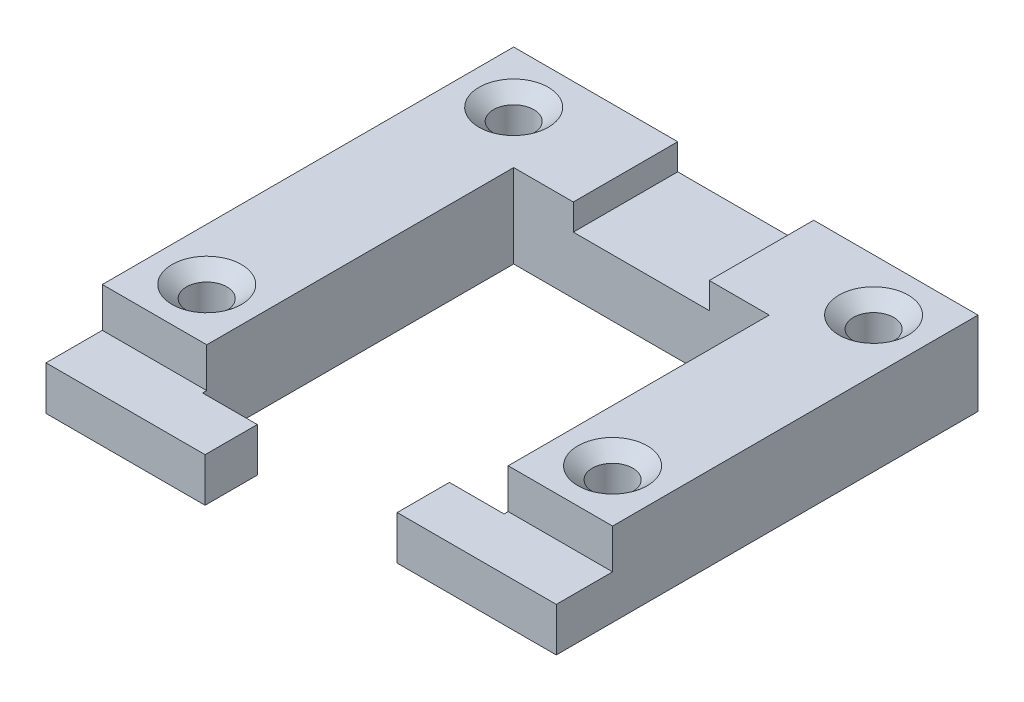
from build123d import *

# Parameters (mm, degrees)
BOSS_EXTRUDE1_DEPTH                               = 10.16
CSK_FOR_8_FLAT_HEAD_MACHINE_SCREW_100_D           = 4.9149
CSK_FOR_8_FLAT_HEAD_MACHINE_SCREW_100_CSINK_D     = 8.4328
CSK_FOR_8_FLAT_HEAD_MACHINE_SCREW_100_CSINK_ANGLE = 100
SKETCH5_W                                         = 16.54
SKETCH5_H                                         = 3.175
CUT_EXTRUDE1_DEPTH                                = 51.038
SKETCH6_W                                         = 12.7
SKETCH6_H                                         = 0.5
BOSS_EXTRUDE2_DEPTH                               = 5.334


with BuildPart() as part:
    # Sketch1 → Boss-Extrude1 (new body)
    with BuildSketch(Plane(origin=(0, 19.05, 0), x_dir=(1, 0, 0), z_dir=(0, 1, 0))):
        Polygon((15.54, 76.2), (15.54, 44.45), (28.24, 44.45), (28.24, 88.9), (-28.24, 88.9), (-28.24, 38.862), (-15.54, 38.862), (-15.54, 76.2), align=None)
    extrude(amount=BOSS_EXTRUDE1_DEPTH)

    # CSK for #8 Flat Head Machine Screw (100)1 (through all)
    with Locations(Plane(origin=(0, 29.21, 0), x_dir=(1, 0, 0), z_dir=(0, 1, 0))):
        with Locations((-21.89, 82.55), (21.89, 82.55), (-21.89, 45.212), (21.89, 50.8)):
            CounterSinkHole(CSK_FOR_8_FLAT_HEAD_MACHINE_SCREW_100_D / 2, CSK_FOR_8_FLAT_HEAD_MACHINE_SCREW_100_CSINK_D / 2, counter_sink_angle=CSK_FOR_8_FLAT_HEAD_MACHINE_SCREW_100_CSINK_ANGLE)

    # Sketch5 → Cut-Extrude1 (cut, through all)
    with BuildSketch(Plane(origin=(0, 0, -88.9), x_dir=(-1, 0, 0), z_dir=(0, 0, -1))):
        with Locations((0.015, 27.6225)):
            Rectangle(SKETCH5_W, SKETCH5_H)
    extrude(amount=-CUT_EXTRUDE1_DEPTH, mode=Mode.SUBTRACT)

    # Sketch6 → Boss-Extrude2 (add)
    with BuildSketch(Plane.XZ.offset(-19.05)):
        with Locations((-21.89, -38.612)):
            Rectangle(SKETCH6_W, SKETCH6_H)
        Polygon((-28.24, -32.012), (-28.24, -38.362), (-15.54, -38.362), (-8.89, -38.362), (-8.89, -32.012), align=None)
        with Locations((21.89, -44.2)):
            Rectangle(SKETCH6_W, SKETCH6_H)
        Polygon((8.89, -43.95), (15.54, -43.95), (28.24, -43.95), (28.24, -37.6), (8.89, -37.6), align=None)
    extrude(amount=-BOSS_EXTRUDE2_DEPTH)


solid = part.part
